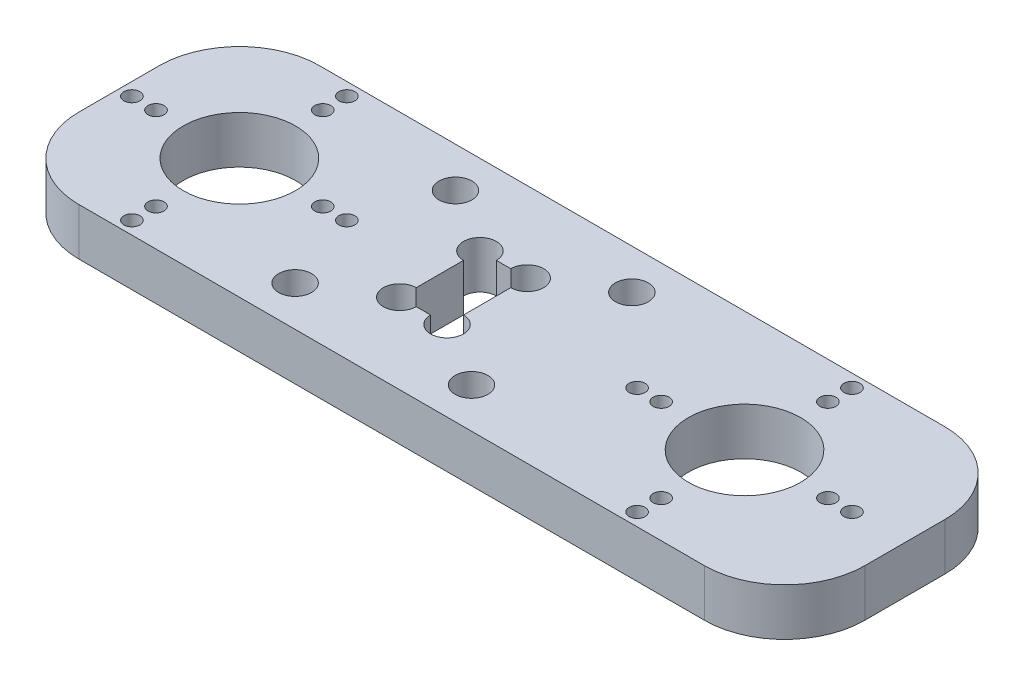
from build123d import *

# Parameters (mm, degrees)
SKETCH1_W           = 98
SKETCH1_H           = 30
SKETCH1_R           = 7
SKETCH1_R_2         = 1
BOSS_EXTRUDE1_DEPTH = 5.9
SKETCH3_W           = 5.9
SKETCH3_H           = 10
CUT_EXTRUDE2_DEPTH  = 10
SKETCH4_R           = 7
SKETCH4_R_2         = 1
CUT_EXTRUDE3_DEPTH  = 10
FILLET1_R           = 10
CUT_EXTRUDE4_REACH  = 7.9
SKETCH5_R           = 2.05
SKETCH6_R           = 2.05
CUT_EXTRUDE5_DEPTH  = 10


with BuildPart() as part:
    # Sketch1 → Boss-Extrude1 (new body)
    with BuildSketch(Plane(origin=(0, 0, 0), x_dir=(1, 0, 0), z_dir=(0, 1, 0))):
        Rectangle(SKETCH1_W, SKETCH1_H)
        with Locations((-34, 0)):
            Circle(SKETCH1_R, mode=Mode.SUBTRACT)
        with Locations((-44.4, 0)):
            Circle(SKETCH1_R_2, mode=Mode.SUBTRACT)
        with Locations((-47.4, 0)):
            Circle(SKETCH1_R_2, mode=Mode.SUBTRACT)
        with Locations((-34, 10.4)):
            Circle(SKETCH1_R_2, mode=Mode.SUBTRACT)
        with Locations((-34, 13.4)):
            Circle(SKETCH1_R_2, mode=Mode.SUBTRACT)
        with Locations((-23.6, 0)):
            Circle(SKETCH1_R_2, mode=Mode.SUBTRACT)
        with Locations((-20.6, 0)):
            Circle(SKETCH1_R_2, mode=Mode.SUBTRACT)
        with Locations((-34, -10.4)):
            Circle(SKETCH1_R_2, mode=Mode.SUBTRACT)
        with Locations((-34, -13.4)):
            Circle(SKETCH1_R_2, mode=Mode.SUBTRACT)
    extrude(amount=BOSS_EXTRUDE1_DEPTH)

    # Sketch3 → Cut-Extrude2 (cut)
    with BuildSketch(Plane(origin=(0, 5.9, 0), x_dir=(1, 0, 0), z_dir=(0, 1, 0))):
        with Locations((-6.05, 0)):
            Rectangle(SKETCH3_W, SKETCH3_H)
    extrude(amount=-CUT_EXTRUDE2_DEPTH, mode=Mode.SUBTRACT)

    # Sketch4 → Cut-Extrude3 (cut)
    with BuildSketch(Plane(origin=(0, 5.9, 0), x_dir=(1, 0, 0), z_dir=(0, 1, 0))):
        with Locations((-34, 0)):
            Circle(SKETCH4_R)
        with Locations((-34, -13.4)):
            Circle(SKETCH4_R_2)
        with Locations((-34, -10.4)):
            Circle(SKETCH4_R_2)
        with Locations((-44.4, 0)):
            Circle(SKETCH4_R_2)
        with Locations((-47.4, 0)):
            Circle(SKETCH4_R_2)
        with Locations((-34, 13.4)):
            Circle(SKETCH4_R_2)
        with Locations((-23.6, 0)):
            Circle(SKETCH4_R_2)
        with Locations((-20.6, 0)):
            Circle(SKETCH4_R_2)
        with Locations((-34, 10.4)):
            Circle(SKETCH4_R_2)
        with Locations((29, -13.4)):
            Circle(SKETCH4_R_2)
        with Locations((29, -10.4)):
            Circle(SKETCH4_R_2)
        with Locations((42.4, 0)):
            Circle(SKETCH4_R_2)
        with Locations((39.4, 0)):
            Circle(SKETCH4_R_2)
        with Locations((29, 0)):
            Circle(SKETCH4_R)
        with Locations((29, 10.4)):
            Circle(SKETCH4_R_2)
        with Locations((29, 13.4)):
            Circle(SKETCH4_R_2)
        with Locations((18.6, 0)):
            Circle(SKETCH4_R_2)
        with Locations((15.6, 0)):
            Circle(SKETCH4_R_2)
    extrude(amount=-CUT_EXTRUDE3_DEPTH, mode=Mode.SUBTRACT)

    # Fillet1
    fillet1_edges = [part.edges().sort_by_distance(p)[0] for p in [
        (49, 2.95, 15),
        (-49, 2.95, 15),
        (-49, 2.95, -15),
        (49, 2.95, -15),
    ]]
    fillet(fillet1_edges, radius=FILLET1_R)

    # Sketch5 → Cut-Extrude4 (cut, up to next)
    with BuildSketch(Plane(origin=(0, 5.9, 0), x_dir=(1, 0, 0), z_dir=(0, 1, 0)), mode=Mode.PRIVATE) as cut_extrude4_sk1:
        with Locations((-9, 5)):
            Circle(SKETCH5_R)
    cut_extrude4_tool1 = extrude(cut_extrude4_sk1.sketch, amount=-CUT_EXTRUDE4_REACH, mode=Mode.PRIVATE) & part.part
    add(cut_extrude4_tool1.solids().sort_by_distance((-9, 5.9, -5))[0], mode=Mode.SUBTRACT)
    # Sketch5 → Cut-Extrude4 (cut, up to next)
    with BuildSketch(Plane(origin=(0, 5.9, 0), x_dir=(1, 0, 0), z_dir=(0, 1, 0)), mode=Mode.PRIVATE) as cut_extrude4_sk2:
        with Locations((-3.1, 5)):
            Circle(SKETCH5_R)
    cut_extrude4_tool2 = extrude(cut_extrude4_sk2.sketch, amount=-CUT_EXTRUDE4_REACH, mode=Mode.PRIVATE) & part.part
    add(cut_extrude4_tool2.solids().sort_by_distance((-3.1, 5.9, -5))[0], mode=Mode.SUBTRACT)
    # Sketch5 → Cut-Extrude4 (cut, up to next)
    with BuildSketch(Plane(origin=(0, 5.9, 0), x_dir=(1, 0, 0), z_dir=(0, 1, 0)), mode=Mode.PRIVATE) as cut_extrude4_sk3:
        with Locations((-3.1, -5)):
            Circle(SKETCH5_R)
    cut_extrude4_tool3 = extrude(cut_extrude4_sk3.sketch, amount=-CUT_EXTRUDE4_REACH, mode=Mode.PRIVATE) & part.part
    add(cut_extrude4_tool3.solids().sort_by_distance((-3.1, 5.9, 5))[0], mode=Mode.SUBTRACT)
    # Sketch5 → Cut-Extrude4 (cut, up to next)
    with BuildSketch(Plane(origin=(0, 5.9, 0), x_dir=(1, 0, 0), z_dir=(0, 1, 0)), mode=Mode.PRIVATE) as cut_extrude4_sk4:
        with Locations((-9, -5)):
            Circle(SKETCH5_R)
    cut_extrude4_tool4 = extrude(cut_extrude4_sk4.sketch, amount=-CUT_EXTRUDE4_REACH, mode=Mode.PRIVATE) & part.part
    add(cut_extrude4_tool4.solids().sort_by_distance((-9, 5.9, 5))[0], mode=Mode.SUBTRACT)

    # Sketch6 → Cut-Extrude5 (cut)
    with BuildSketch(Plane(origin=(0, 5.9, 0), x_dir=(1, 0, 0), z_dir=(0, 1, 0))):
        with Locations((-17.05, 10)):
            Circle(SKETCH6_R)
        with Locations((-17.05, -10)):
            Circle(SKETCH6_R)
        with Locations((4.95, -10)):
            Circle(SKETCH6_R)
        with Locations((4.95, 10)):
            Circle(SKETCH6_R)
    extrude(amount=-CUT_EXTRUDE5_DEPTH, mode=Mode.SUBTRACT)


solid = part.part
